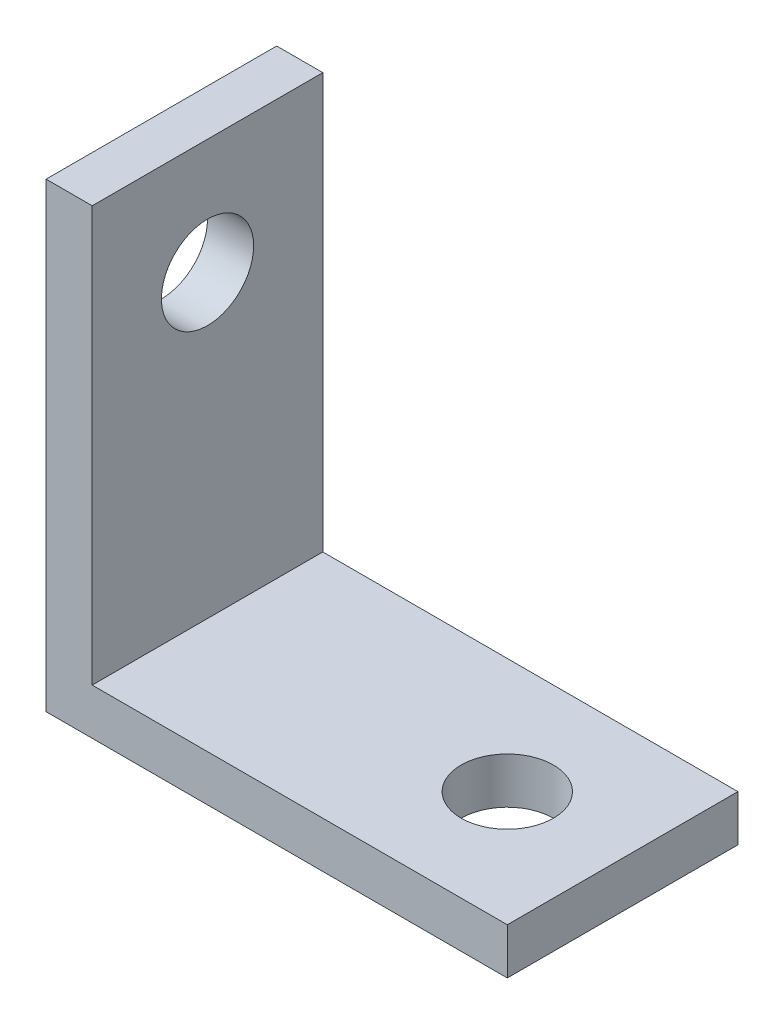
from build123d import *

# Parameters (mm, degrees)
SKETCH1_W           = 2
SKETCH1_H           = 18
SKETCH1_H_2         = 2
SKETCH1_W_2         = 18
BOSS_EXTRUDE2_DEPTH = 10
SKETCH3_R           = 2
CUT_EXTRUDE1_DEPTH  = 3
SKETCH4_R           = 2
CUT_EXTRUDE2_DEPTH  = 3


with BuildPart() as part:
    # Sketch1 → Boss-Extrude2 (new body)
    with BuildSketch(Plane.XY):
        with Locations((-8.840572317, 11)):
            Rectangle(SKETCH1_W, SKETCH1_H)
        with Locations((-8.840572317, 1)):
            Rectangle(SKETCH1_W, SKETCH1_H_2)
        with Locations((1.159427683, 1)):
            Rectangle(SKETCH1_W_2, SKETCH1_H_2)
    extrude(amount=BOSS_EXTRUDE2_DEPTH)

    # Sketch3 → Cut-Extrude1 (cut, through all)
    with BuildSketch(Plane(origin=(0, 2, 0), x_dir=(1, 0, 0), z_dir=(0, 1, 0))):
        with Locations((5.159427683, -5)):
            Circle(SKETCH3_R)
    extrude(amount=-CUT_EXTRUDE1_DEPTH, mode=Mode.SUBTRACT)

    # Sketch4 → Cut-Extrude2 (cut, through all)
    with BuildSketch(Plane(origin=(-7.840572317, 0, 0), x_dir=(0, 0, -1), z_dir=(1, 0, 0))):
        with Locations((-5, 15)):
            Circle(SKETCH4_R)
    extrude(amount=-CUT_EXTRUDE2_DEPTH, mode=Mode.SUBTRACT)


solid = part.part
